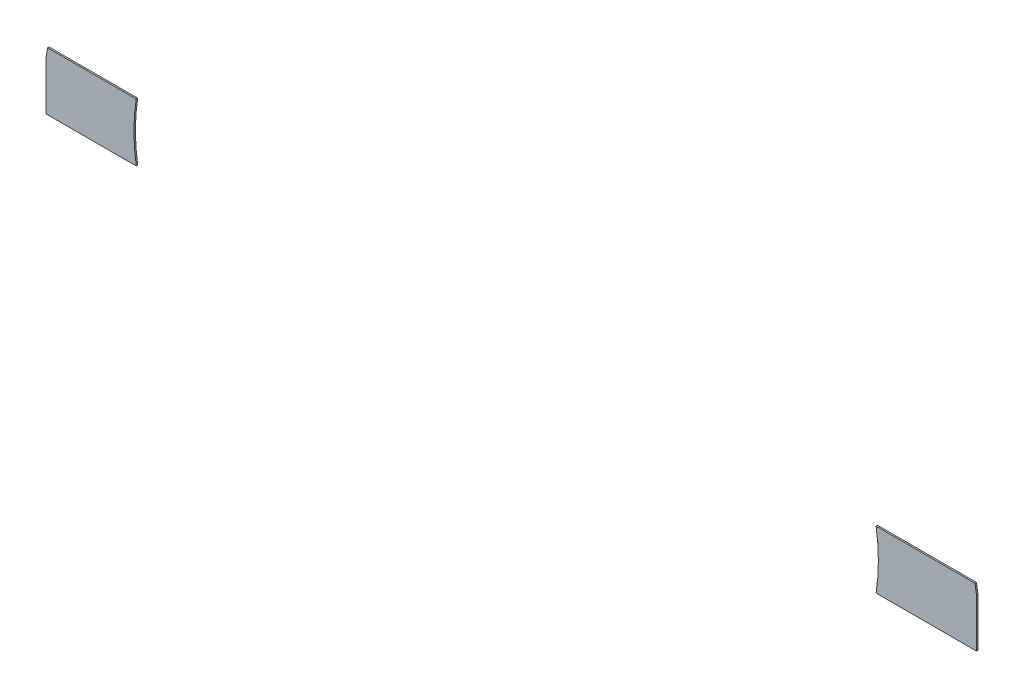
from build123d import *

# Parameters (mm, degrees)
SALIENTE_EXTRUIR1_DEPTH   = 0.1
SALIENTE_EXTRUIR1_2_DEPTH = 0.1


with BuildPart() as part:
    # Model → Saliente-Extruir1 (new body)
    with BuildSketch(Plane.XY):
        with BuildLine():
            Line((85.186650916, 21.357722957), (85.186650916, 24.664118021))
            ThreePointArc((85.186650916, 24.664118021), (85.137193195, 25.011198527), (85.083978887, 25.357722957))
            Line((85.083978887, 25.357722957), (78.263745687, 25.357722957))
            ThreePointArc((78.263745687, 25.357722957), (78.420630281, 23.357722957), (78.263745687, 21.357722957))
            Line((78.263745687, 21.357722957), (85.186650916, 21.357722957))
        make_face()
    extrude(amount=SALIENTE_EXTRUIR1_DEPTH)


with BuildPart() as body_2:
    # Model → Saliente-Extruir1 2 (new body)
    with BuildSketch(Plane.XY):
        with BuildLine():
            Line((27.270848208, 25.357722957), (21.155989611, 25.357722957))
            ThreePointArc((21.155989611, 25.357722957), (21.102775302, 25.011198527), (21.053317582, 24.664118021))
            Line((21.053317582, 24.664118021), (21.053317582, 21.357722957))
            Line((21.053317582, 21.357722957), (27.270848208, 21.357722957))
            ThreePointArc((27.270848208, 21.357722957), (27.113963614, 23.357722957), (27.270848208, 25.357722957))
        make_face()
    extrude(amount=SALIENTE_EXTRUIR1_2_DEPTH)


solid = Compound([part.part, body_2.part])
